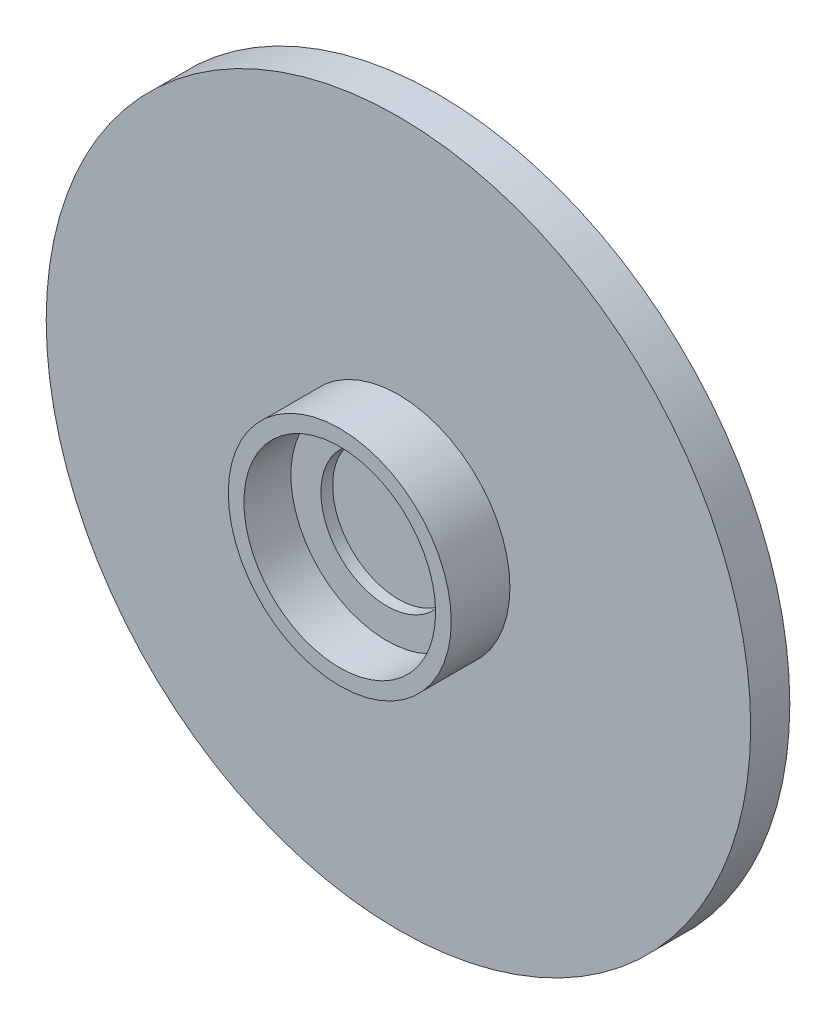
from build123d import *

# Parameters (mm, degrees)
SKETCH1_R           = 90.043
BOSS_EXTRUDE1_DEPTH = 10
SKETCH3_W           = 40
SKETCH3_H           = 10
BOSS_EXTRUDE2_DEPTH = 40
BOSS_EXTRUDE5_DEPTH = 5
SKETCH5_R           = 28.5
SKETCH5_R_2         = 24.5
BOSS_EXTRUDE6_DEPTH = 15
SKETCH6_R           = 24.5
SKETCH6_R_2         = 16.821657313
BOSS_EXTRUDE7_DEPTH = 3


with BuildPart() as part:
    # Sketch1 → Boss-Extrude1 (new body)
    with BuildSketch(Plane.XY):
        Circle(SKETCH1_R)
    extrude(amount=BOSS_EXTRUDE1_DEPTH)

    # Sketch3 → Boss-Extrude2 (add)
    with BuildSketch(Plane(origin=(0, 0, 0), x_dir=(-1, 0, 0), z_dir=(0, 0, -1))):
        with Locations((0, -40)):
            Rectangle(SKETCH3_W, SKETCH3_H)
    extrude(amount=BOSS_EXTRUDE2_DEPTH)

    # Sketch4 → Boss-Extrude5 (add)
    with BuildSketch(Plane.ZY.offset(20)):
        Polygon((-40, -35), (0, -15.575750454), (0, -20.206895082), (-30.463169004, -35), align=None)
    boss_extrude5 = extrude(amount=-BOSS_EXTRUDE5_DEPTH)

    # Mirror1: Boss-Extrude5 across plane
    add(boss_extrude5.mirror(Plane(origin=(0, 0, 0), x_dir=(0, 0, 1), z_dir=(1, 0, 0))))

    # Sketch5 → Boss-Extrude6 (add)
    with BuildSketch(Plane.XY.offset(10)):
        Circle(SKETCH5_R)
        Circle(SKETCH5_R_2, mode=Mode.SUBTRACT)
    extrude(amount=BOSS_EXTRUDE6_DEPTH)

    # Sketch6 → Boss-Extrude7 (add)
    with BuildSketch(Plane.XY.offset(10)):
        Circle(SKETCH6_R)
        Circle(SKETCH6_R_2, mode=Mode.SUBTRACT)
    extrude(amount=BOSS_EXTRUDE7_DEPTH)


solid = part.part
